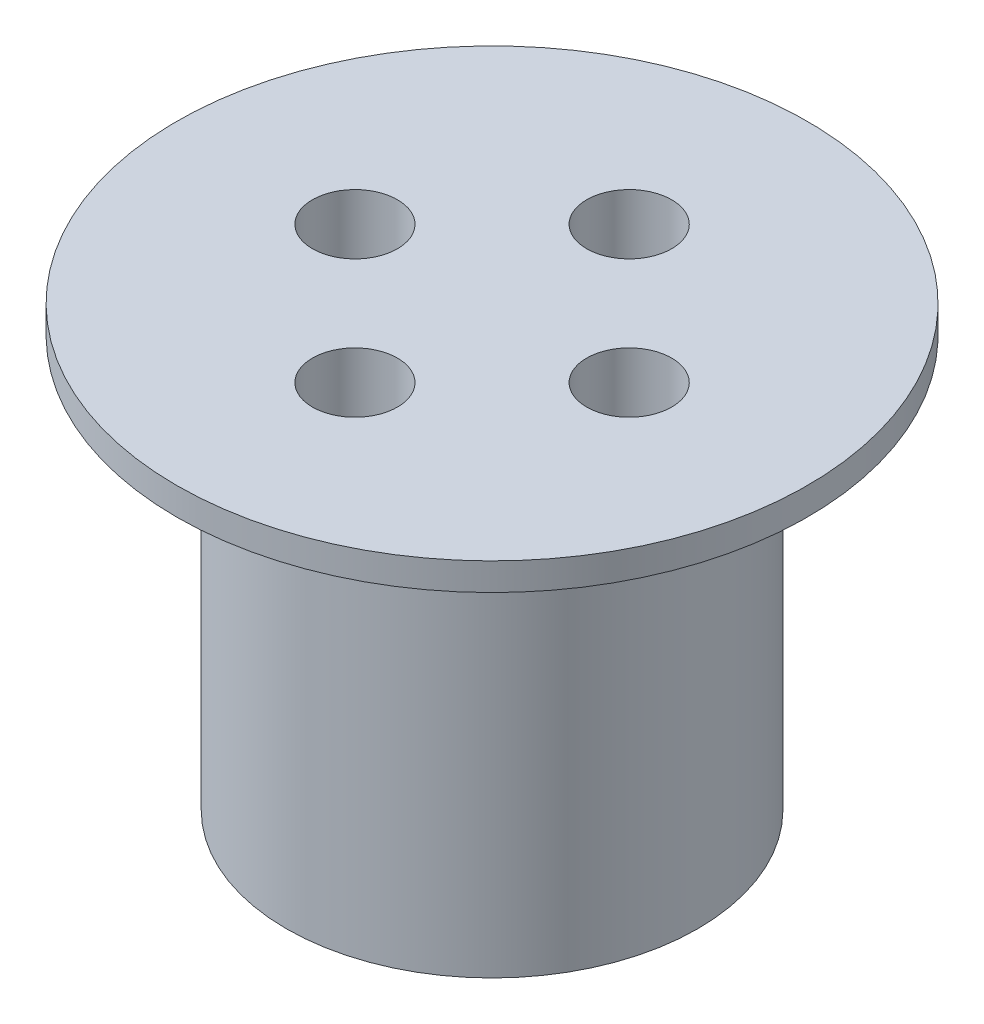
from build123d import *

# Parameters (mm, degrees)
SKETCH1_R           = 15
BOSS_EXTRUDE1_DEPTH = 30
SKETCH2_R           = 23
BOSS_EXTRUDE2_DEPTH = 2
SKETCH3_R           = 2.25
CUT_EXTRUDE1_DEPTH  = 10
SKETCH4_R           = 3.1
CUT_EXTRUDE2_DEPTH  = 10


with BuildPart() as part:
    # Sketch1 → Boss-Extrude1 (new body)
    with BuildSketch(Plane(origin=(0, 0, 0), x_dir=(1, 0, 0), z_dir=(0, 1, 0))):
        Circle(SKETCH1_R)
    extrude(amount=BOSS_EXTRUDE1_DEPTH)

    # Sketch2 → Boss-Extrude2 (add)
    with BuildSketch(Plane(origin=(0, 30, 0), x_dir=(1, 0, 0), z_dir=(0, 1, 0))):
        Circle(SKETCH2_R)
    extrude(amount=BOSS_EXTRUDE2_DEPTH)

    # Sketch3 → Cut-Extrude1 (cut)
    with BuildSketch(Plane.XZ):
        with Locations((0, 10)):
            Circle(SKETCH3_R)
        with Locations((10, 0)):
            Circle(SKETCH3_R)
        with Locations((0, -10)):
            Circle(SKETCH3_R)
        with Locations((-10, 0)):
            Circle(SKETCH3_R)
    extrude(amount=-CUT_EXTRUDE1_DEPTH, mode=Mode.SUBTRACT)

    # Sketch4 → Cut-Extrude2 (cut)
    with BuildSketch(Plane(origin=(0, 32, 0), x_dir=(1, 0, 0), z_dir=(0, 1, 0))):
        with Locations((0, 10)):
            Circle(SKETCH4_R)
        with Locations((10, 0)):
            Circle(SKETCH4_R)
        with Locations((0, -10)):
            Circle(SKETCH4_R)
        with Locations((-10, 0)):
            Circle(SKETCH4_R)
    extrude(amount=-CUT_EXTRUDE2_DEPTH, mode=Mode.SUBTRACT)


solid = part.part
